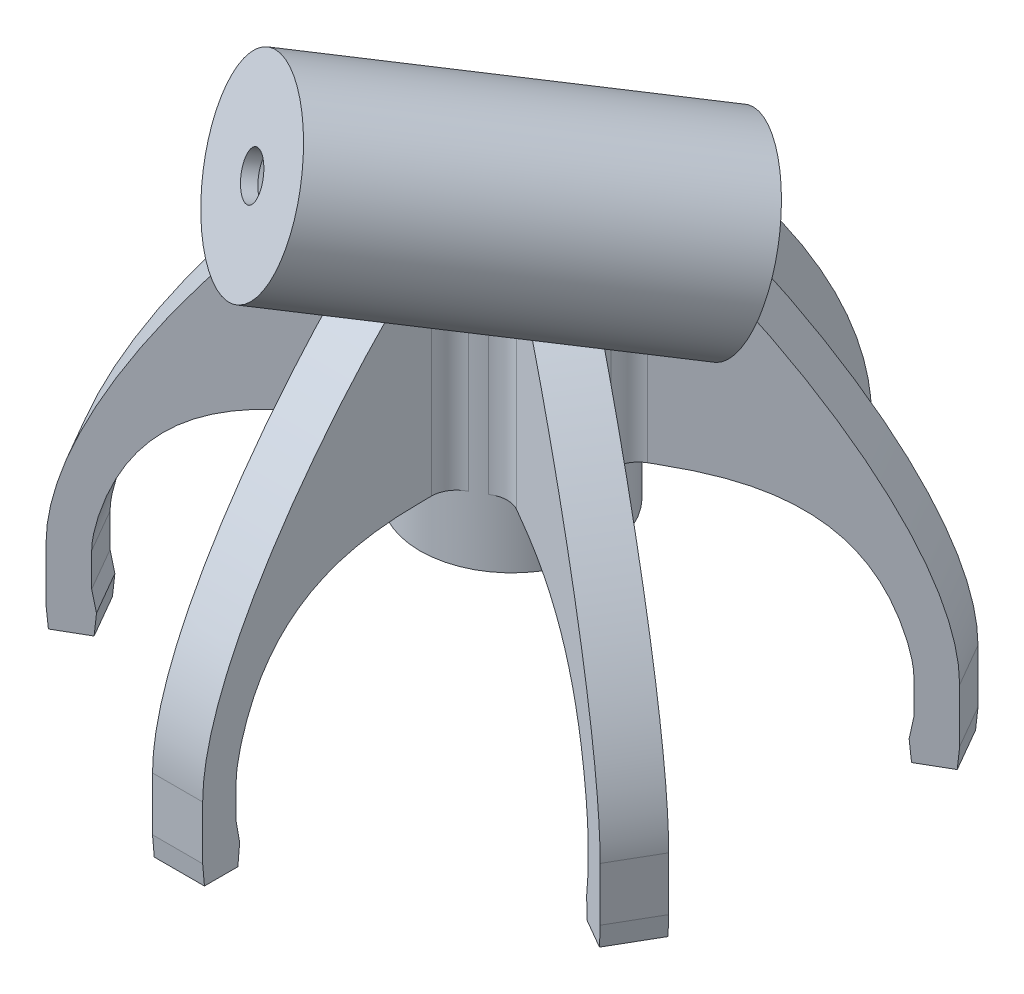
from build123d import *

# Parameters (mm, degrees)
SKETCH1_R                = 5.5
SKETCH1_R_2              = 1.25
BOSS_EXTRUDE1_DEPTH      = 16
BOSS_EXTRUDE2_DEPTH      = 1.5
BOSS_EXTRUDE3_DEPTH      = 3
CIRPATTERN1_COUNT        = 5
CIRPATTERN1_ANGLE        = 240
FILLET1_R                = 1.5
SKETCH6_R                = 3.5
CUT_EXTRUDE1_DEPTH       = 15.2
SKETCH10_R               = 5.5
SKETCH10_R_2             = 1.25
BOSS_EXTRUDE4_DEPTH      = 16
BOSS_EXTRUDE4_DEPTH_BACK = 6
BOSS_EXTRUDE10_REACH     = 16.574
SKETCH11_R               = 3.5
CUT_EXTRUDE2_DEPTH       = 21.2


with BuildPart() as part:
    # Sketch1 → Boss-Extrude1 (new body)
    with BuildSketch(Plane(origin=(0, 0, 0), x_dir=(1, 0, 0), z_dir=(0, 1, 0))):
        Circle(SKETCH1_R)
        Circle(SKETCH1_R_2, mode=Mode.SUBTRACT)
    extrude(amount=BOSS_EXTRUDE1_DEPTH)

    # Sketch2 → Boss-Extrude2 (add, symmetric)
    with BuildSketch(Plane(origin=(0, 0, 0), x_dir=(0, 0, -1), z_dir=(1, 0, 0))):
        with BuildLine():
            Line((18, -5), (20, -5))
            add(Edge.make_bspline(
                [(8.914213562, 14.585786438), (13.074333826, 10.425666174), (20, 1.461761402), (20, -5)],
                knots=[0.14734609, 0.14734609, 0.14734609, 0.14734609, 1, 1, 1, 1], degree=3))
            Line((8.914213562, 14.585786438), (7.5, 16))
            Line((7.5, 16), (5.5, 16))
            Line((5.5, 16), (1.25, 16))
            Line((1.25, 16), (1.25, 4))
            Line((1.25, 4), (6.70571865, 4))
            add(Edge.make_bspline(
                [(6.70571865, 4), (10.522194615, 4), (16.021169224, 3.257262603), (18, -4.005650027), (18, -5)],
                knots=[0, 0, 0, 0, 0.785490543, 1, 1, 1, 1], degree=3))
        make_face()
    boss_extrude2 = extrude(amount=BOSS_EXTRUDE2_DEPTH, both=True)

    # Sketch8 → Boss-Extrude3 (add)
    with BuildSketch(Plane(origin=(1.5, 0, 0), x_dir=(0, 0, -1), z_dir=(1, 0, 0))):
        Polygon((18, -7), (17.788407623, -8.2), (17.894203812, -9.409255967), (19.894203812, -9.409255967), (20, -8.2), (20, -7), (20, -5), (18, -5), align=None)
    boss_extrude3 = extrude(amount=-BOSS_EXTRUDE3_DEPTH)

    # CirPattern1: Boss-Extrude2, Boss-Extrude3 ×5 about axis
    cirpattern1_axis = Axis((0, 16, 0), (0, -1, 0))
    for i in range(1, CIRPATTERN1_COUNT):
        add(boss_extrude2.rotate(cirpattern1_axis, i * CIRPATTERN1_ANGLE / (CIRPATTERN1_COUNT - 1)))
        add(boss_extrude3.rotate(cirpattern1_axis, i * CIRPATTERN1_ANGLE / (CIRPATTERN1_COUNT - 1)))

    # Fillet1
    fillet1_edges = [part.edges().sort_by_distance(p)[0] for p in [
        (-5.332575695, 10, 1.346713205),
        (1.5, 10, -5.291502622),
        (-1.5, 10, -5.291502622),
        (3.832575695, 10, -3.944789417),
        (5.332575695, 10, 1.346713205),
        (1.5, 10, 5.291502622),
        (-3.832575695, 10, 3.944789417),
        (5.332575695, 10, -1.346713205),
        (3.832575695, 10, 3.944789417),
        (-1.5, 10, 5.291502622),
    ]]
    fillet(fillet1_edges, radius=FILLET1_R)

    # Sketch6 → Cut-Extrude1 (cut)
    with BuildSketch(Plane(origin=(0, 16, 0), x_dir=(1, 0, 0), z_dir=(0, 1, 0))):
        Circle(SKETCH6_R)
    extrude(amount=-CUT_EXTRUDE1_DEPTH, mode=Mode.SUBTRACT)

    # Sketch10 → Boss-Extrude4 (add, two sides)
    with BuildSketch(Plane(origin=(-2.351141009, 1.527864045, 4.072295684), x_dir=(0.866025404, 0, 0.5), z_dir=(-0.475528258, 0.309016994, 0.823639104))) as boss_extrude4_sk:
        with Locations((9, 19.842637557)):
            Circle(SKETCH10_R)
        with Locations((9, 19.842637557)):
            Circle(SKETCH10_R_2, mode=Mode.SUBTRACT)
    extrude(amount=BOSS_EXTRUDE4_DEPTH)
    extrude(boss_extrude4_sk.sketch, amount=-BOSS_EXTRUDE4_DEPTH_BACK)

    # Sketch16 → Boss-Extrude10 (add, up to next)
    with BuildSketch(Plane(origin=(0, 16, 0), x_dir=(1, 0, 0), z_dir=(0, 1, 0)), mode=Mode.PRIVATE) as boss_extrude10_sk1:
        with BuildLine():
            Line((6.350852961, 4), (-0.288675135, -7.5))
            Line((-0.288675135, -7.5), (1.5, -7.5))
            Line((1.5, -7.5), (1.5, -6.32455532))
            ThreePointArc((1.5, -6.32455532), (1.732268618, -5.522771595), (2.357142857, -4.969293466))
            ThreePointArc((2.357142857, -4.969293466), (2.75, -4.763139721), (3.124962952, -4.525992328))
            ThreePointArc((3.124962952, -4.525992328), (3.305889272, -4.418971164), (3.5, -4.338293482))
            ThreePointArc((3.5, -4.338293482), (4.126842059, -4.267834221), (4.727225575, -4.461315766))
            Line((4.727225575, -4.461315766), (5.23810468, -4.756271954))
            add(Edge.make_bspline(
                [(5.522613217, -0.930402058), (5.049152923, -3.22167428), (5.23810468, -4.756271954)],
                knots=[5.532424046, 5.532424046, 5.532424046, 5.894267037, 5.894267037, 5.894267037], degree=2, weights=[1, 0.9836783, 1]))
            ThreePointArc((5.522613217, -0.930402058), (5.482385541, -0.688512638), (5.482105809, -0.443301138))
            ThreePointArc((5.482105809, -0.443301138), (5.5, 0), (5.482105809, 0.443301138))
            ThreePointArc((5.482105809, 0.443301138), (5.648994809, 1.261197168), (6.227225575, 1.863239554))
            Line((6.227225575, 1.863239554), (6.278306217, 1.892730977))
            add(Edge.make_bspline(
                [(6.759951788, 3.291420046), (6.498738058, 2.578407465), (6.278306217, 1.892730977)],
                knots=[5.225610557, 5.225610557, 5.225610557, 5.322030654, 5.322030654, 5.322030654], degree=2, weights=[1, 0.998838121, 1]))
            Line((6.759951788, 3.291420046), (6.350852961, 4))
        make_face()
    boss_extrude10_tool1 = extrude(boss_extrude10_sk1.sketch, amount=BOSS_EXTRUDE10_REACH, mode=Mode.PRIVATE) - part.part
    add(boss_extrude10_tool1.solids().sort_by_distance((3.702235, 16, 2.406075))[0])

    # Sketch11 → Cut-Extrude2 (cut)
    with BuildSketch(Plane(origin=(0.50202854, -0.326237921, -0.869538938), x_dir=(-0.879643998, -0.156424143, -0.449174715), z_dir=(0.475528258, -0.309016994, -0.823639104))):
        with Locations((-12.14103215, 18.092142039)):
            Circle(SKETCH11_R)
    extrude(amount=-CUT_EXTRUDE2_DEPTH, mode=Mode.SUBTRACT)


solid = part.part
